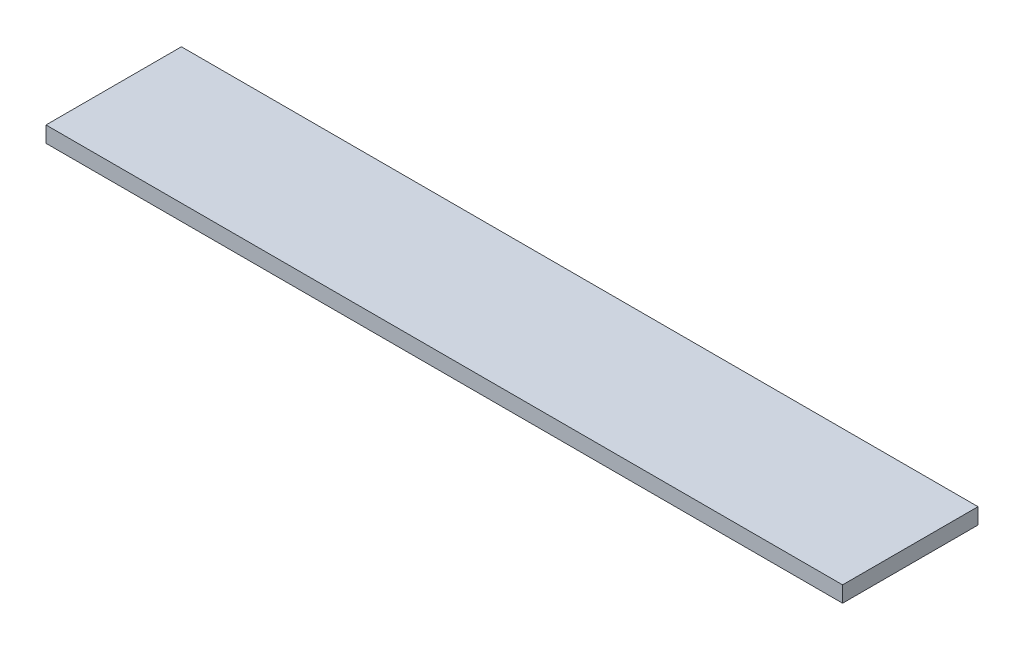
from build123d import *

# Parameters (mm, degrees)
SKETCH1_W           = 500
SKETCH1_H           = 85
BOSS_EXTRUDE1_DEPTH = 10


with BuildPart() as part:
    # Sketch1 → Boss-Extrude1 (new body)
    with BuildSketch(Plane(origin=(0, 0, 0), x_dir=(1, 0, 0), z_dir=(0, 1, 0))):
        Rectangle(SKETCH1_W, SKETCH1_H)
    extrude(amount=-BOSS_EXTRUDE1_DEPTH)


solid = part.part
